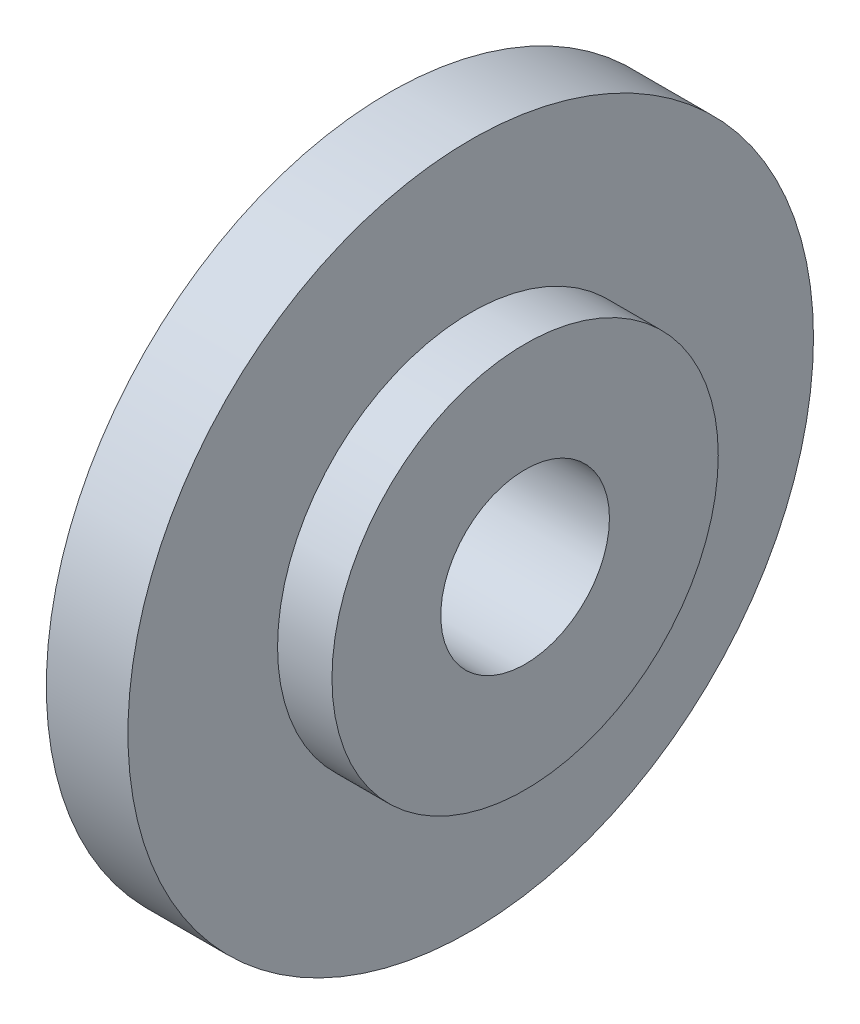
from build123d import *

# Parameters (mm, degrees)
SKETCH1_R           = 12.6
SKETCH1_R_2         = 7.1
BOSS_EXTRUDE1_DEPTH = 3
SKETCH1_4_R         = 7.1
SKETCH1_4_R_2       = 3.1
BOSS_EXTRUDE2_DEPTH = 5


with BuildPart() as part:
    # Sketch1 → Boss-Extrude1 (new body)
    with BuildSketch(Plane(origin=(0, 0, 0), x_dir=(0, 0, -1), z_dir=(1, 0, 0))):
        Circle(SKETCH1_R)
        Circle(SKETCH1_R_2, mode=Mode.SUBTRACT)
    extrude(amount=BOSS_EXTRUDE1_DEPTH)

    # Sketch1_4 → Boss-Extrude2 (add)
    with BuildSketch(Plane(origin=(0, 0, 0), x_dir=(0, 0, -1), z_dir=(1, 0, 0))):
        Circle(SKETCH1_4_R)
        Circle(SKETCH1_4_R_2, mode=Mode.SUBTRACT)
    extrude(amount=BOSS_EXTRUDE2_DEPTH)


solid = part.part
